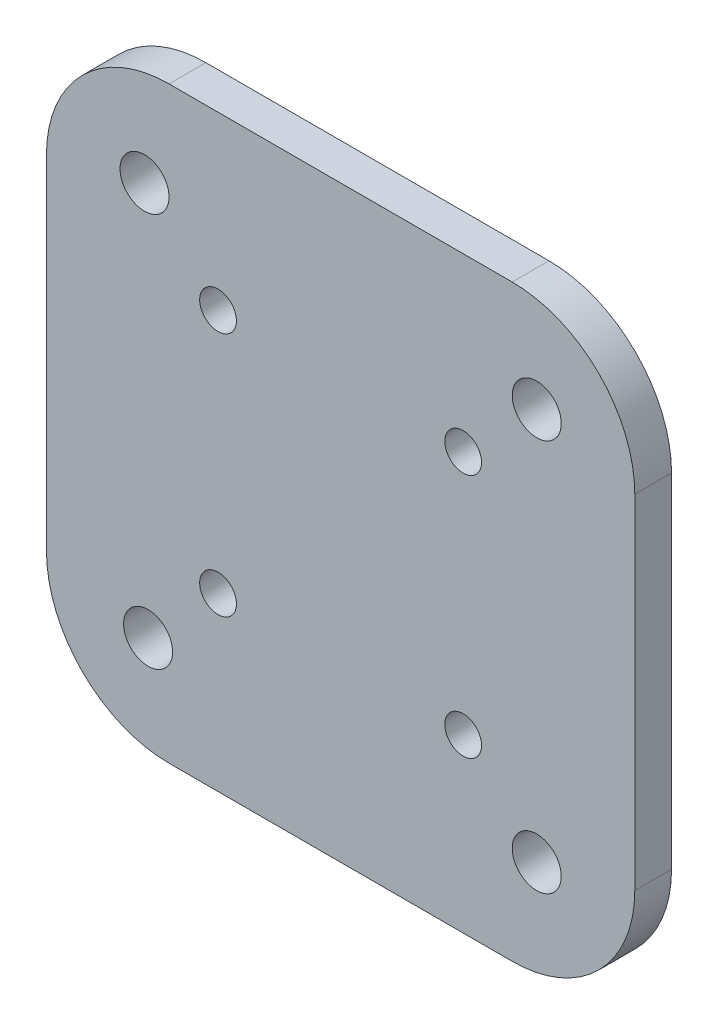
from build123d import *

# Parameters (mm, degrees)
SKETCH1_W           = 48
SKETCH1_H           = 48
SKETCH1_R           = 1.5
SKETCH1_R_2         = 2
BOSS_EXTRUDE1_DEPTH = 3
FILLET1_R           = 10
FILLET2_R           = 10
FILLET3_R           = 10
FILLET4_R           = 10


with BuildPart() as part:
    # Sketch1 → Boss-Extrude1 (new body)
    with BuildSketch(Plane.XY):
        Rectangle(SKETCH1_W, SKETCH1_H)
        with Locations((10, 10)):
            Circle(SKETCH1_R, mode=Mode.SUBTRACT)
        with Locations((-10, 10)):
            Circle(SKETCH1_R, mode=Mode.SUBTRACT)
        with Locations((-10, -10)):
            Circle(SKETCH1_R, mode=Mode.SUBTRACT)
        with Locations((10, -10)):
            Circle(SKETCH1_R, mode=Mode.SUBTRACT)
        with Locations((-16, 16)):
            Circle(SKETCH1_R_2, mode=Mode.SUBTRACT)
        with Locations((16, 16)):
            Circle(SKETCH1_R_2, mode=Mode.SUBTRACT)
        with Locations((16, -16)):
            Circle(SKETCH1_R_2, mode=Mode.SUBTRACT)
        with Locations((-15.708422677, -16)):
            Circle(SKETCH1_R_2, mode=Mode.SUBTRACT)
    extrude(amount=BOSS_EXTRUDE1_DEPTH)

    # Fillet1
    fillet1_edges = [part.edges().sort_by_distance(p)[0] for p in [
        (-24, 24, 1.5),
    ]]
    fillet(fillet1_edges, radius=FILLET1_R)

    # Fillet2
    fillet2_edges = [part.edges().sort_by_distance(p)[0] for p in [
        (24, 24, 1.5),
    ]]
    fillet(fillet2_edges, radius=FILLET2_R)

    # Fillet3
    fillet3_edges = [part.edges().sort_by_distance(p)[0] for p in [
        (24, -24, 1.5),
    ]]
    fillet(fillet3_edges, radius=FILLET3_R)

    # Fillet4
    fillet4_edges = [part.edges().sort_by_distance(p)[0] for p in [
        (-24, -24, 1.5),
    ]]
    fillet(fillet4_edges, radius=FILLET4_R)


solid = part.part
